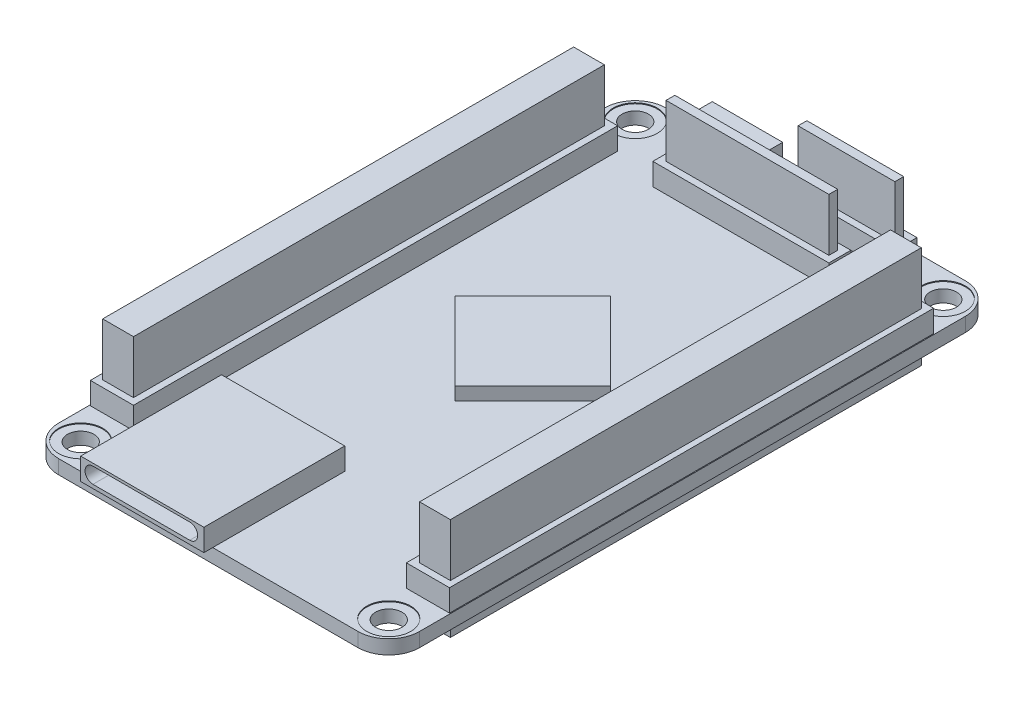
from build123d import *

# Parameters (mm, degrees)
SKETCH_1_W          = 41
SKETCH_1_H          = 69
EXTRUDE_1_DEPTH     = 1.6
SKETCH_3_R          = 2.5
CUT_EXTRUDE_1_DEPTH = 0.1
FILLET_4_R          = 3.5
SKETCH_4_R          = 1.5
CUT_EXTRUDE_2_DEPTH = 1.9
SKETCH_5_W          = 4.9
SKETCH_5_H          = 55
EXTRUDE_2_DEPTH     = 2.5
SKETCH_6_W          = 4.9
SKETCH_6_H          = 55
EXTRUDE_3_DEPTH     = 2.5
SKETCH_7_W          = 20
SKETCH_7_H          = 2.5
EXTRUDE_4_DEPTH     = 2.5
SKETCH_8_W          = 12.5
SKETCH_8_H          = 2.5
EXTRUDE_5_DEPTH     = 2.5
SKETCH_9_W          = 8
SKETCH_9_H          = 5
EXTRUDE_6_DEPTH     = 2.5
CUT_EXTRUDE_3_DEPTH = 4
EXTRUDE_7_DEPTH     = 1.5
SKETCH_12_W         = 3.5
SKETCH_12_H         = 53.5
EXTRUDE_8_DEPTH     = 6
SKETCH_13_W         = 3.5
SKETCH_13_H         = 53.5
EXTRUDE_9_DEPTH     = 6
SKETCH_14_W         = 18.5
SKETCH_14_H         = 1
EXTRUDE_10_DEPTH    = 6
SKETCH_15_W         = 11
SKETCH_15_H         = 1
EXTRUDE_11_DEPTH    = 6
SKETCH_16_W         = 3.5
SKETCH_16_H         = 53.5
SKETCH_16_W_2       = 18.5
SKETCH_16_H_2       = 1
SKETCH_16_W_3       = 11
EXTRUDE_12_DEPTH    = 1.5
SKETCH_17_R         = 2.5
CUT_EXTRUDE_4_DEPTH = 0.1
SKETCH_18_W         = 14
SKETCH_18_H         = 16
EXTRUDE_13_DEPTH    = 2.5
CUT_EXTRUDE_5_DEPTH = 15


with BuildPart() as part:
    # Эскиз1 → Бобышка-Вытянуть1 (new body)
    with BuildSketch(Plane(origin=(0, 0, 0), x_dir=(1, 0, 0), z_dir=(0, 1, 0))):
        with Locations((6.8125, -2.44375)):
            Rectangle(SKETCH_1_W, SKETCH_1_H)
    extrude(amount=EXTRUDE_1_DEPTH)

    # Эскиз3 → Вырез-Вытянуть1 (cut)
    with BuildSketch(Plane(origin=(0, 1.6, 0), x_dir=(1, 0, 0), z_dir=(0, 1, 0))):
        with Locations((-10.6875, 29.05625)):
            Circle(SKETCH_3_R)
        with Locations((24.3125, 29.05625)):
            Circle(SKETCH_3_R)
        with Locations((-10.6875, -33.94375)):
            Circle(SKETCH_3_R)
        with Locations((24.3125, -33.94375)):
            Circle(SKETCH_3_R)
    extrude(amount=-CUT_EXTRUDE_1_DEPTH, mode=Mode.SUBTRACT)

    # Скругление4
    fillet_4_edges = [part.edges().sort_by_distance(p)[0] for p in [
        (-13.6875, 0.8, -32.05625),
        (27.3125, 0.8, -32.05625),
        (27.3125, 0.8, 36.94375),
        (-13.6875, 0.8, 36.94375),
    ]]
    fillet(fillet_4_edges, radius=FILLET_4_R)

    # Эскиз4 → Вырез-Вытянуть2 (cut)
    with BuildSketch(Plane(origin=(0, 1.5, 0), x_dir=(1, 0, 0), z_dir=(0, 1, 0))):
        with Locations((-10.6875, 29.05625)):
            Circle(SKETCH_4_R)
        with Locations((24.3125, 29.05625)):
            Circle(SKETCH_4_R)
        with Locations((-10.6875, -33.94375)):
            Circle(SKETCH_4_R)
        with Locations((24.3125, -33.94375)):
            Circle(SKETCH_4_R)
    extrude(amount=-CUT_EXTRUDE_2_DEPTH, mode=Mode.SUBTRACT)

    # Эскиз5 → Бобышка-Вытянуть2 (add)
    with BuildSketch(Plane(origin=(0, 1.6, 0), x_dir=(1, 0, 0), z_dir=(0, 1, 0))):
        with Locations((-11.1375, -2.44375)):
            Rectangle(SKETCH_5_W, SKETCH_5_H)
    extrude(amount=EXTRUDE_2_DEPTH)

    # Эскиз6 → Бобышка-Вытянуть3 (add)
    with BuildSketch(Plane(origin=(0, 1.6, 0), x_dir=(1, 0, 0), z_dir=(0, 1, 0))):
        with Locations((24.7625, -2.44375)):
            Rectangle(SKETCH_6_W, SKETCH_6_H)
    extrude(amount=EXTRUDE_3_DEPTH)

    # Эскиз7 → Бобышка-Вытянуть4 (add)
    with BuildSketch(Plane(origin=(0, 1.6, 0), x_dir=(1, 0, 0), z_dir=(0, 1, 0))):
        with Locations((6.8125, 24.80625)):
            Rectangle(SKETCH_7_W, SKETCH_7_H)
    extrude(amount=EXTRUDE_4_DEPTH)

    # Эскиз8 → Бобышка-Вытянуть5 (add)
    with BuildSketch(Plane(origin=(0, 1.6, 0), x_dir=(1, 0, 0), z_dir=(0, 1, 0))):
        with Locations((13.0625, 29.80625)):
            Rectangle(SKETCH_8_W, SKETCH_8_H)
    extrude(amount=EXTRUDE_5_DEPTH)

    # Эскиз9 → Бобышка-Вытянуть6 (add)
    with BuildSketch(Plane(origin=(0, 1.6, 0), x_dir=(1, 0, 0), z_dir=(0, 1, 0))):
        with Locations((-1.6875, 30.30625)):
            Rectangle(SKETCH_9_W, SKETCH_9_H)
    extrude(amount=EXTRUDE_6_DEPTH)

    # Эскиз10 → Вырез-Вытянуть3 (cut)
    with BuildSketch(Plane(origin=(0, 0, -32.80625), x_dir=(-1, 0, 0), z_dir=(0, 0, -1))):
        with BuildLine():
            Line((-0.715104459, 3.393132584), (4.188395452, 3.393132584))
            ThreePointArc((4.188395452, 3.393132584), (4.827982397, 2.753545639), (4.188395452, 2.113958694))
            Line((4.188395452, 2.113958694), (-0.715104459, 2.113958694))
            ThreePointArc((-0.715104459, 2.113958694), (-1.354691404, 2.753545639), (-0.715104459, 3.393132584))
        make_face()
    extrude(amount=-CUT_EXTRUDE_3_DEPTH, mode=Mode.SUBTRACT)

    # Эскиз11 → Бобышка-Вытянуть7 (add)
    with BuildSketch(Plane(origin=(0, 1.6, 0), x_dir=(1, 0, 0), z_dir=(0, 1, 0))):
        Polygon((-2.1875, 0.05625), (6.651334765, 8.895084765), (15.49016953, 0.05625), (6.651334765, -8.782584765), align=None)
    extrude(amount=EXTRUDE_7_DEPTH)

    # Эскиз12 → Бобышка-Вытянуть8 (add)
    with BuildSketch(Plane(origin=(0, 4.1, 0), x_dir=(1, 0, 0), z_dir=(0, 1, 0))):
        with Locations((-11.1875, -2.44375)):
            Rectangle(SKETCH_12_W, SKETCH_12_H)
    extrude(amount=EXTRUDE_8_DEPTH)

    # Эскиз13 → Бобышка-Вытянуть9 (add)
    with BuildSketch(Plane(origin=(0, 4.1, 0), x_dir=(1, 0, 0), z_dir=(0, 1, 0))):
        with Locations((24.8125, -2.44375)):
            Rectangle(SKETCH_13_W, SKETCH_13_H)
    extrude(amount=EXTRUDE_9_DEPTH)

    # Эскиз14 → Бобышка-Вытянуть10 (add)
    with BuildSketch(Plane(origin=(0, 4.1, 0), x_dir=(1, 0, 0), z_dir=(0, 1, 0))):
        with Locations((6.8125, 24.80625)):
            Rectangle(SKETCH_14_W, SKETCH_14_H)
    extrude(amount=EXTRUDE_10_DEPTH)

    # Эскиз15 → Бобышка-Вытянуть11 (add)
    with BuildSketch(Plane(origin=(0, 4.1, 0), x_dir=(1, 0, 0), z_dir=(0, 1, 0))):
        with Locations((13.0625, 29.80625)):
            Rectangle(SKETCH_15_W, SKETCH_15_H)
    extrude(amount=EXTRUDE_11_DEPTH)

    # Эскиз16 → Бобышка-Вытянуть12 (add)
    with BuildSketch(Plane(origin=(0, 0, 0), x_dir=(-1, 0, 0), z_dir=(0, -1, 0))):
        with Locations((11.1875, -2.44375)):
            Rectangle(SKETCH_16_W, SKETCH_16_H)
        with Locations((-24.8125, -2.44375)):
            Rectangle(SKETCH_16_W, SKETCH_16_H)
        with Locations((-6.8125, 24.80625)):
            Rectangle(SKETCH_16_W_2, SKETCH_16_H_2)
        with Locations((-13.0625, 29.80625)):
            Rectangle(SKETCH_16_W_3, SKETCH_16_H_2)
    extrude(amount=EXTRUDE_12_DEPTH)

    # Эскиз17 → Вырез-Вытянуть4 (cut)
    with BuildSketch(Plane(origin=(0, 0, 0), x_dir=(-1, 0, 0), z_dir=(0, -1, 0))):
        with Locations((10.6875, -33.94375)):
            Circle(SKETCH_17_R)
        with Locations((-24.3125, -33.94375)):
            Circle(SKETCH_17_R)
        with Locations((10.6875, 29.05625)):
            Circle(SKETCH_17_R)
        with Locations((-24.3125, 29.05625)):
            Circle(SKETCH_17_R)
    extrude(amount=-CUT_EXTRUDE_4_DEPTH, mode=Mode.SUBTRACT)

    # Эскиз18 → Бобышка-Вытянуть13 (add)
    with BuildSketch(Plane(origin=(0, 1.6, 0), x_dir=(1, 0, 0), z_dir=(0, 1, 0))):
        with Locations((0.3125, -29.94375)):
            Rectangle(SKETCH_18_W, SKETCH_18_H)
    extrude(amount=EXTRUDE_13_DEPTH)

    # Эскиз19 → Вырез-Вытянуть5 (cut)
    with BuildSketch(Plane.XY.offset(37.94375)):
        with BuildLine():
            Line((-5.297012823, 3.809650009), (5.703882629, 3.809650009))
            ThreePointArc((5.703882629, 3.809650009), (6.599304352, 2.914228286), (5.703882629, 2.018806563))
            Line((5.703882629, 2.018806563), (-5.297012823, 2.018806563))
            ThreePointArc((-5.297012823, 2.018806563), (-6.192434546, 2.914228286), (-5.297012823, 3.809650009))
        make_face()
    extrude(amount=-CUT_EXTRUDE_5_DEPTH, mode=Mode.SUBTRACT)


solid = part.part
